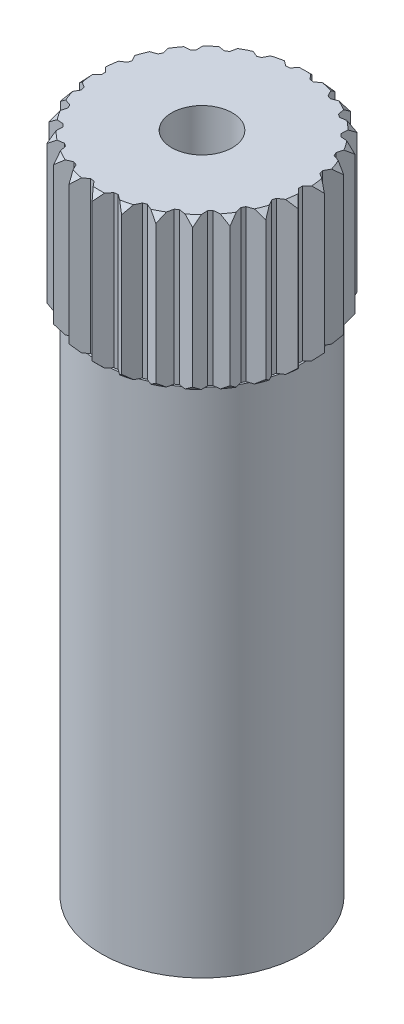
from build123d import *

# Parameters (mm, degrees)
SHAFTS_R              = 2.9
SHAFT_DEPTH           = 13.5
SHAFTEXTENSIONS_R     = 2.6
SHAFT_EXTENSION_DEPTH = 4
TOOTH_DEPTH           = 17.5
TOOTH_CP_COUNT        = 26
SMALLBORES_R          = 0.8
SMALL_BORE_DEPTH      = 4
SHAFTUNDERCUTS_W      = 0.25
SHAFTUNDERCUTS_H      = 13.5


with BuildPart() as part:
    # ShaftS → SHAFT (new body)
    with BuildSketch(Plane(origin=(0, 0, 0), x_dir=(1, 0, 0), z_dir=(0, 1, 0))):
        Circle(SHAFTS_R)
    extrude(amount=SHAFT_DEPTH)

    # ShaftExtensionS → SHAFT EXTENSION (add)
    with BuildSketch(Plane(origin=(0, 13.5, 0), x_dir=(1, 0, 0), z_dir=(0, 1, 0))):
        Circle(SHAFTEXTENSIONS_R)
    extrude(amount=SHAFT_EXTENSION_DEPTH)

    # ToothS → TOOTH (add)
    with BuildSketch(Plane(origin=(0, 17.5, 0), x_dir=(1, 0, 0), z_dir=(0, 1, 0))):
        with BuildLine():
            Line((0, 2.9), (-0.262912611, 2.586672952))
            ThreePointArc((-0.262912611, 2.586672952), (0, 2.6), (0.262912611, 2.586672952))
            Line((0.262912611, 2.586672952), (0, 2.9))
        make_face()
    tooth = extrude(amount=-TOOTH_DEPTH)

    # TOOTH CP: TOOTH ×26 about axis
    tooth_cp_axis = Axis((0, 0, 0), (0, 1, 0))
    for i in range(1, TOOTH_CP_COUNT):
        add(tooth.rotate(tooth_cp_axis, i * 360 / TOOTH_CP_COUNT))

    # SmallBoreS → SMALL BORE (cut)
    with BuildSketch(Plane(origin=(0, 17.5, 0), x_dir=(1, 0, 0), z_dir=(0, 1, 0))):
        Circle(SMALLBORES_R)
    extrude(amount=-SMALL_BORE_DEPTH, mode=Mode.SUBTRACT)

    # ShaftUnderCutS → SHAFT UNDER CUT (revolve, cut)
    with BuildSketch(Plane.XY):
        with Locations((2.775, 6.75)):
            Rectangle(SHAFTUNDERCUTS_W, SHAFTUNDERCUTS_H)
    revolve(axis=Axis((0, 13.5, 0), (0, -1, 0)), mode=Mode.SUBTRACT)

    # TeethChamferS → TEETH CHAMFER (revolve, cut)
    with BuildSketch(Plane(origin=(0, 0, 0), x_dir=(0, 0, -1), z_dir=(1, 0, 0))):
        Polygon((2.9, 17.323223305), (2.9, 17.5), (2.723223305, 17.5), align=None)
        Polygon((2.723223305, 13.5), (2.9, 13.676776695), (2.9, 13.5), align=None)
    revolve(axis=Axis((0, 13.5, 0), (0, 1, 0)), mode=Mode.SUBTRACT)


solid = part.part
